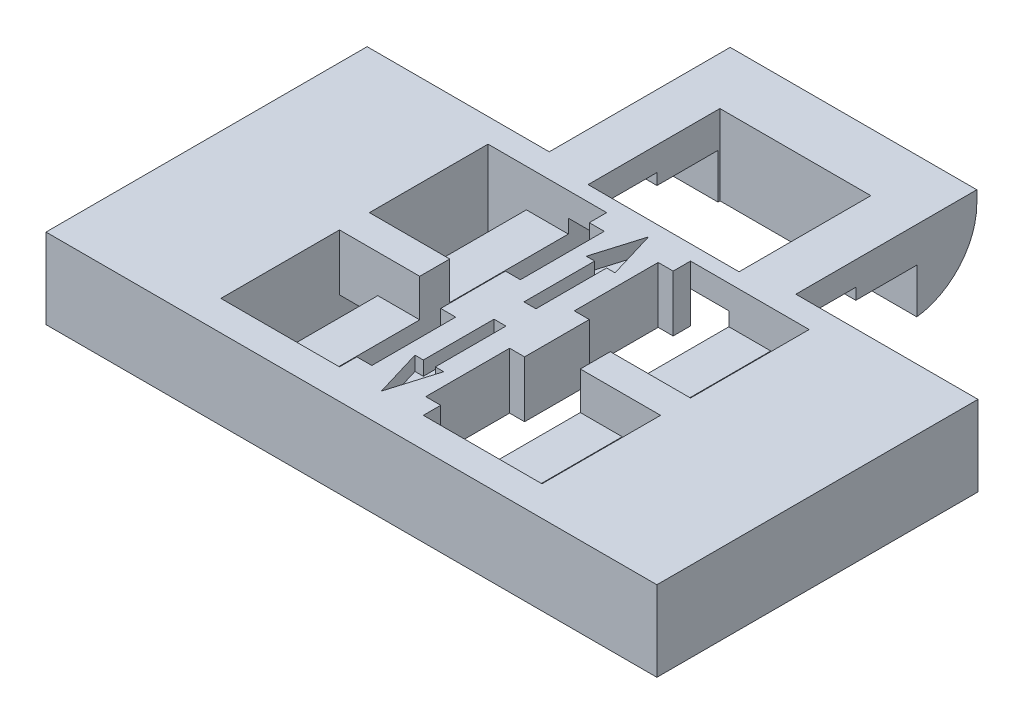
from build123d import *

# Parameters (mm, degrees)
SKETCH1_W               = 64.75
SKETCH1_H               = 84.325
SKETCH1_R               = 1.35
BOSS_EXTRUDE1_DEPTH     = 25.4
CUT_EXTRUDE1_DEPTH      = 65.75
SKETCH5_W               = 58.925
SKETCH5_H               = 20.6375
CUT_EXTRUDE3_DEPTH      = 65.75
BOSS_EXTRUDE2_START     = 4.7625
SKETCH1_3_W             = 6.75
SKETCH1_3_H             = 6.75
SKETCH1_3_R             = 1.35
SKETCH1_3_H_2           = 3.175
BOSS_EXTRUDE2_DEPTH     = 6.35
SKETCH7_W               = 26.65
SKETCH7_H               = 58.925
CUT_EXTRUDE6_DEPTH      = 13.7
CUT_EXTRUDE6_DEPTH_BACK = 13.7
SKETCH8_W               = 64.75
SKETCH8_H               = 34.036
SKETCH8_W_2             = 4.064
SKETCH8_H_2             = 12.573
BOSS_EXTRUDE3_DEPTH     = 8.5
CUT_EXTRUDE7_START      = -8.5
SKETCH8_3_W             = 4.445
SKETCH8_3_H             = 12.573
CUT_EXTRUDE7_DEPTH      = 4
SKETCH8_4_W             = 4.445
SKETCH8_4_H             = 12.573
CUT_EXTRUDE8_DEPTH      = 2.54
SKETCH9_W               = 26.65
SKETCH9_H               = 86.865
SKETCH9_W_2             = 8.509
SKETCH9_H_2             = 3.175
CUT_EXTRUDE9_DEPTH      = 2.54
CUT_EXTRUDE10_DEPTH     = 1.5
SKETCH11_W              = 64.75
SKETCH11_H              = 84.325
CUT_EXTRUDE11_DEPTH     = 26.4
BOSS_EXTRUDE4_DEPTH     = 64.75
SKETCH15_W              = 19.304
SKETCH15_H              = 19.177
SKETCH15_W_2            = 16
SKETCH15_H_2            = 13.97
CUT_EXTRUDE12_DEPTH     = 9.5
SKETCH17_W              = 17.018
SKETCH17_H              = 2.54
CUT_EXTRUDE13_DEPTH     = 5.96


with BuildPart() as part:
    # Sketch1 → Boss-Extrude1 (new body)
    with BuildSketch(Plane(origin=(0, 0, 0), x_dir=(1, 0, 0), z_dir=(0, 1, 0))):
        Rectangle(SKETCH1_W, SKETCH1_H)
        with Locations((-29, 10.2125)):
            Circle(SKETCH1_R, mode=Mode.SUBTRACT)
        with Locations((-29, -38.7875)):
            Circle(SKETCH1_R, mode=Mode.SUBTRACT)
        with Locations((29, 10.2125)):
            Circle(SKETCH1_R, mode=Mode.SUBTRACT)
        with Locations((29, -38.7875)):
            Circle(SKETCH1_R, mode=Mode.SUBTRACT)
    extrude(amount=BOSS_EXTRUDE1_DEPTH)

    # Sketch3 → Cut-Extrude1 (cut, through all)
    with BuildSketch(Plane(origin=(32.375, 0, 0), x_dir=(0, 0, -1), z_dir=(1, 0, 0))):
        Polygon((42.1625, 18.034), (23.1125, 18.669), (23.1125, 12.7), (42.1625, 12.7), align=None)
    extrude(amount=-CUT_EXTRUDE1_DEPTH, mode=Mode.SUBTRACT)

    # Sketch5 → Cut-Extrude3 (cut, through all)
    with BuildSketch(Plane(origin=(32.375, 0, 0), x_dir=(0, 0, -1), z_dir=(1, 0, 0))):
        with Locations((-12.7, 15.08125)):
            Rectangle(SKETCH5_W, SKETCH5_H)
    extrude(amount=-CUT_EXTRUDE3_DEPTH, mode=Mode.SUBTRACT)

    # Sketch1_3 → Boss-Extrude2 (add)
    with BuildSketch(Plane(origin=(0, 0, 0), x_dir=(1, 0, 0), z_dir=(0, 1, 0)).offset(BOSS_EXTRUDE2_START)):
        with Locations((29, -38.7875)):
            Rectangle(SKETCH1_3_W, SKETCH1_3_H)
        with Locations((29, -38.7875)):
            Circle(SKETCH1_3_R, mode=Mode.SUBTRACT)
        with Locations((-29, -38.7875)):
            Rectangle(SKETCH1_3_W, SKETCH1_3_H)
        with Locations((-29, -38.7875)):
            Circle(SKETCH1_3_R, mode=Mode.SUBTRACT)
        with Locations((-29, 10.2125)):
            Rectangle(SKETCH1_3_W, SKETCH1_3_H)
        with Locations((-29, 10.2125)):
            Circle(SKETCH1_3_R, mode=Mode.SUBTRACT)
        with Locations((29, 10.2125)):
            Rectangle(SKETCH1_3_W, SKETCH1_3_H)
        with Locations((29, 10.2125)):
            Circle(SKETCH1_3_R, mode=Mode.SUBTRACT)
        with Locations((-29, 15.175)):
            Rectangle(SKETCH1_3_W, SKETCH1_3_H_2)
        with Locations((29, 15.175)):
            Rectangle(SKETCH1_3_W, SKETCH1_3_H_2)
    extrude(amount=BOSS_EXTRUDE2_DEPTH)

    # Sketch7 → Cut-Extrude6 (cut, two sides)
    with BuildSketch(Plane(origin=(0, 12.7, 0), x_dir=(1, 0, 0), z_dir=(0, 1, 0))) as cut_extrude6_sk:
        Rectangle(SKETCH7_W, SKETCH7_H)
    extrude(amount=CUT_EXTRUDE6_DEPTH, mode=Mode.SUBTRACT)
    extrude(cut_extrude6_sk.sketch, amount=-CUT_EXTRUDE6_DEPTH_BACK, mode=Mode.SUBTRACT)

    # Sketch8 → Boss-Extrude3 (add)
    with BuildSketch(Plane.XZ):
        with Locations((0, 59.1805)):
            Rectangle(SKETCH8_W, SKETCH8_H)
        with Locations((-14.986, 50.989)):
            Rectangle(SKETCH8_W_2, SKETCH8_H_2, mode=Mode.SUBTRACT)
        with Locations((-14.986, 66.737)):
            Rectangle(SKETCH8_W_2, SKETCH8_H_2, mode=Mode.SUBTRACT)
        Polygon((-8.509, 73.0235), (-4.445, 73.0235), (-4.445, 71.182), (-2.8575, 71.182), (-2.8575, 62.292), (-4.445, 62.292), (-4.445, 55.434), (-2.8575, 55.434), (-2.8575, 46.544), (-4.445, 46.544), (-4.445, 44.7025), (-8.509, 44.7025), align=None, mode=Mode.SUBTRACT)
        Polygon((4.445, 73.0235), (8.509, 73.0235), (8.509, 44.7025), (4.445, 44.7025), (4.445, 46.544), (2.8575, 46.544), (2.8575, 55.434), (4.445, 55.434), (4.445, 62.292), (2.8575, 62.292), (2.8575, 71.182), (4.445, 71.182), align=None, mode=Mode.SUBTRACT)
        with Locations((14.986, 66.737)):
            Rectangle(SKETCH8_W_2, SKETCH8_H_2, mode=Mode.SUBTRACT)
        with Locations((14.986, 50.989)):
            Rectangle(SKETCH8_W_2, SKETCH8_H_2, mode=Mode.SUBTRACT)
    extrude(amount=-BOSS_EXTRUDE3_DEPTH)

    # Sketch8_3 → Cut-Extrude7 (cut)
    with BuildSketch(Plane.XZ.offset(CUT_EXTRUDE7_START)):
        with Locations((-10.7315, 50.989)):
            Rectangle(SKETCH8_3_W, SKETCH8_3_H)
        with Locations((10.7315, 50.989)):
            Rectangle(SKETCH8_3_W, SKETCH8_3_H)
        with Locations((-10.7315, 66.737)):
            Rectangle(SKETCH8_3_W, SKETCH8_3_H)
        with Locations((10.7315, 66.737)):
            Rectangle(SKETCH8_3_W, SKETCH8_3_H)
    extrude(amount=CUT_EXTRUDE7_DEPTH, mode=Mode.SUBTRACT)

    # Sketch8_4 → Cut-Extrude8 (cut)
    with BuildSketch(Plane.XZ):
        with Locations((10.7315, 50.989)):
            Rectangle(SKETCH8_4_W, SKETCH8_4_H)
        with Locations((-10.7315, 50.989)):
            Rectangle(SKETCH8_4_W, SKETCH8_4_H)
        with Locations((10.7315, 66.737)):
            Rectangle(SKETCH8_4_W, SKETCH8_4_H)
        with Locations((-10.7315, 66.737)):
            Rectangle(SKETCH8_4_W, SKETCH8_4_H)
        Polygon((-4.445, 46.544), (-4.445, 44.7025), (4.445, 44.7025), (4.445, 46.544), (2.8575, 46.544), (2.8575, 49.084), (2.8575, 52.894), (2.8575, 55.434), (4.445, 55.434), (4.445, 57.2755), (4.445, 60.4505), (4.445, 62.292), (2.8575, 62.292), (2.8575, 64.832), (2.8575, 68.642), (2.8575, 71.182), (4.445, 71.182), (4.445, 73.0235), (-4.445, 73.0235), (-4.445, 71.182), (-2.8575, 71.182), (-2.8575, 68.642), (-2.8575, 64.832), (-2.8575, 62.292), (-4.445, 62.292), (-4.445, 60.4505), (-4.445, 57.2755), (-4.445, 55.434), (-2.8575, 55.434), (-2.8575, 52.894), (-2.8575, 49.084), (-2.8575, 46.544), align=None)
    extrude(amount=-CUT_EXTRUDE8_DEPTH, mode=Mode.SUBTRACT)

    # Sketch9 → Cut-Extrude9 (cut)
    with BuildSketch(Plane.XZ):
        with Locations((0, 1.27)):
            Rectangle(SKETCH9_W, SKETCH9_H)
        with Locations((-12.7635, 58.863)):
            Rectangle(SKETCH9_W_2, SKETCH9_H_2)
        with Locations((12.7635, 58.863)):
            Rectangle(SKETCH9_W_2, SKETCH9_H_2)
    extrude(amount=-CUT_EXTRUDE9_DEPTH, mode=Mode.SUBTRACT)

    # Sketch10 → Cut-Extrude10 (cut)
    with BuildSketch(Plane(origin=(0, 8.5, 0), x_dir=(1, 0, 0), z_dir=(0, 1, 0))):
        Polygon((-0.635, -57.2755), (0.635, -57.2755), (0.635, -49.7825), (1.524, -49.7825), (0, -44.7025), (-1.524, -49.7825), (-0.635, -49.7825), align=None)
        Polygon((-0.635, -67.9435), (-0.635, -60.4505), (0.635, -60.4505), (0.635, -67.9435), (1.524, -67.9435), (0, -73.0235), (-1.524, -67.9435), align=None)
    extrude(amount=-CUT_EXTRUDE10_DEPTH, mode=Mode.SUBTRACT)

    # Sketch11 → Cut-Extrude11 (cut, through all)
    with BuildSketch(Plane.XZ):
        Rectangle(SKETCH11_W, SKETCH11_H)
    extrude(amount=-CUT_EXTRUDE11_DEPTH, mode=Mode.SUBTRACT)

    # Sketch14 → Boss-Extrude4 (add)
    with BuildSketch(Plane(origin=(32.375, 0, 0), x_dir=(0, 0, -1), z_dir=(1, 0, 0))):
        with BuildLine():
            Line((-22.9855, 8.5), (-42.1625, 8.5))
            Line((-42.1625, 8.5), (-42.1625, 5.96))
            Line((-42.1625, 5.96), (-35.8125, 5.96))
            Line((-35.8125, 5.96), (-35.8125, 4.7625))
            Line((-35.8125, 4.7625), (-29.3355, 4.7625))
            Line((-29.3355, 4.7625), (-29.3355, 0))
            ThreePointArc((-29.3355, 0), (-24.798384872, 2.418674819), (-22.9855, 7.23))
            Line((-22.9855, 7.23), (-22.9855, 8.5))
        make_face()
    extrude(amount=-BOSS_EXTRUDE4_DEPTH)

    # Sketch15 → Cut-Extrude12 (cut, through all)
    with BuildSketch(Plane(origin=(0, 8.5, 0), x_dir=(1, 0, 0), z_dir=(0, 1, 0))):
        with Locations((-22.723, -32.574)):
            Rectangle(SKETCH15_W, SKETCH15_H)
        with Locations((0, -36.13)):
            Rectangle(SKETCH15_W_2, SKETCH15_H_2)
        with Locations((22.723, -32.574)):
            Rectangle(SKETCH15_W, SKETCH15_H)
    extrude(amount=-CUT_EXTRUDE12_DEPTH, mode=Mode.SUBTRACT)

    # Sketch17 → Cut-Extrude13 (cut)
    with BuildSketch(Plane.XZ):
        with Locations((0, 43.4325)):
            Rectangle(SKETCH17_W, SKETCH17_H)
    extrude(amount=-CUT_EXTRUDE13_DEPTH, mode=Mode.SUBTRACT)


solid = part.part
